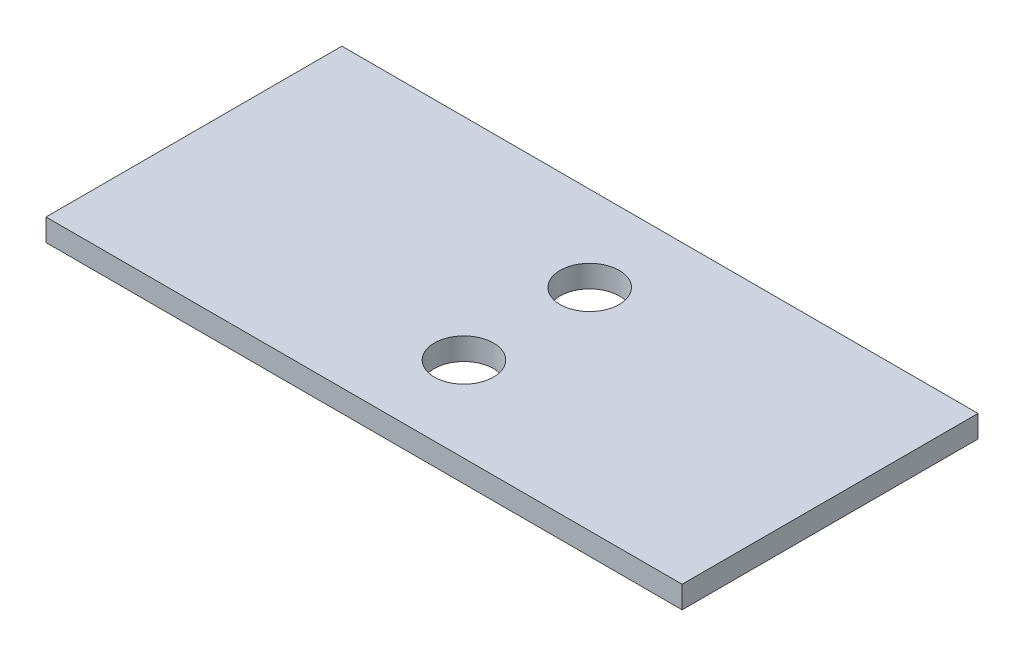
from build123d import *

# Parameters (mm, degrees)
SKETCH_1_W      = 43
SKETCH_1_H      = 20
SKETCH_1_R      = 2
EXTRUDE_1_DEPTH = 1.5


with BuildPart() as part:
    # Эскиз1 → Бобышка-Вытянуть1 (new body)
    with BuildSketch(Plane(origin=(0, 0, 0), x_dir=(1, 0, 0), z_dir=(0, 1, 0))):
        with Locations((21.5, 10)):
            Rectangle(SKETCH_1_W, SKETCH_1_H)
        with Locations((22.5, 14.25)):
            Circle(SKETCH_1_R, mode=Mode.SUBTRACT)
        with Locations((22.5, 5.75)):
            Circle(SKETCH_1_R, mode=Mode.SUBTRACT)
    extrude(amount=EXTRUDE_1_DEPTH)


solid = part.part
